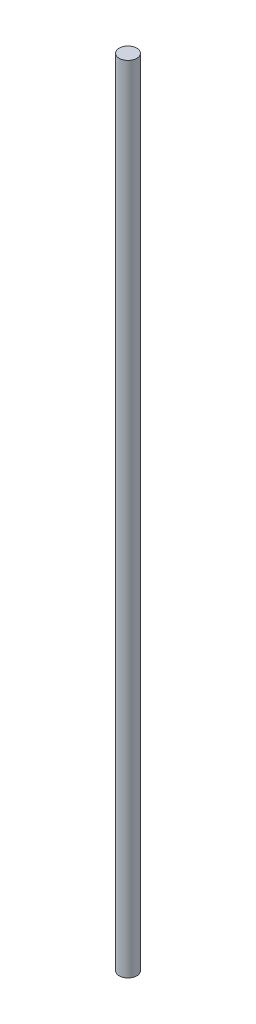
from build123d import *

# Parameters (mm, degrees)
SKETCH1_R           = 4
BOSS_EXTRUDE1_DEPTH = 360


with BuildPart() as part:
    # Sketch1 → Boss-Extrude1 (new body)
    with BuildSketch(Plane(origin=(0, 0, 0), x_dir=(1, 0, 0), z_dir=(0, 1, 0))):
        Circle(SKETCH1_R)
    extrude(amount=BOSS_EXTRUDE1_DEPTH)


solid = part.part
